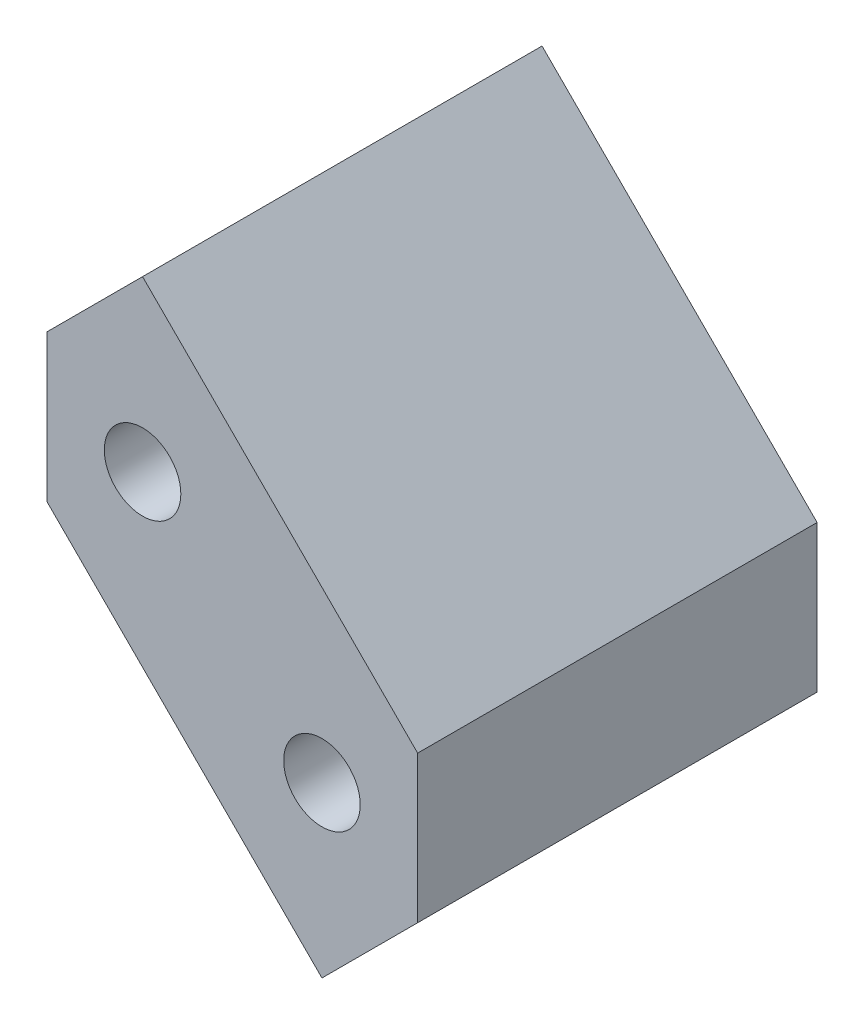
from build123d import *

# Parameters (mm, degrees)
SKETCH1_R           = 1.6
BOSS_EXTRUDE1_DEPTH = 16.7


with BuildPart() as part:
    # Sketch1 → Boss-Extrude1 (new body)
    with BuildSketch(Plane.XY):
        Polygon((7.75, -0.678932188), (-3.75, 10.821067812), (-7.75, 6.821067812), (-7.75, 0.678932188), (3.75, -10.821067812), (7.75, -6.821067812), align=None)
        with Locations((3.75, -3.75)):
            Circle(SKETCH1_R, mode=Mode.SUBTRACT)
        with Locations((-3.75, 3.75)):
            Circle(SKETCH1_R, mode=Mode.SUBTRACT)
    extrude(amount=BOSS_EXTRUDE1_DEPTH)


solid = part.part
